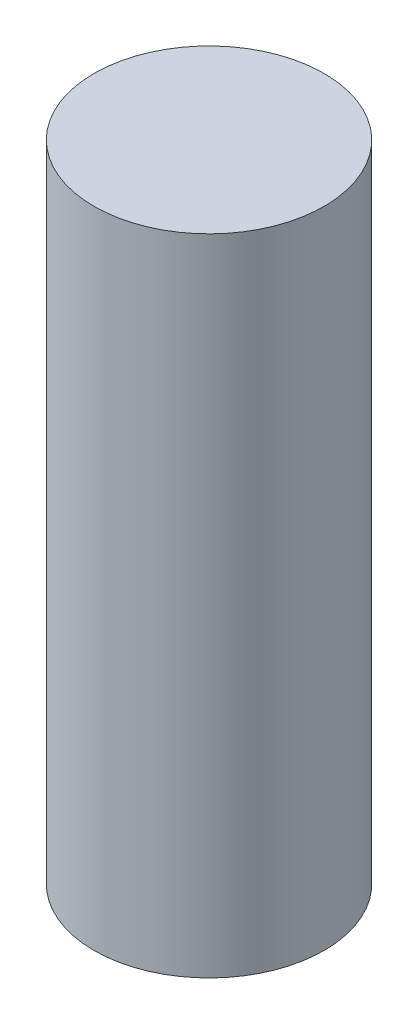
from build123d import *

# Parameters (mm, degrees)
ESBO_O1_R                = 2
RESSALTO_EXTRUS_O1_DEPTH = 5.6


with BuildPart() as part:
    # Esboço1 → Ressalto-extrusão1 (new body, symmetric)
    with BuildSketch(Plane(origin=(0, 0, 0), x_dir=(1, 0, 0), z_dir=(0, 1, 0))):
        Circle(ESBO_O1_R)
    extrude(amount=RESSALTO_EXTRUS_O1_DEPTH, both=True)


solid = part.part
